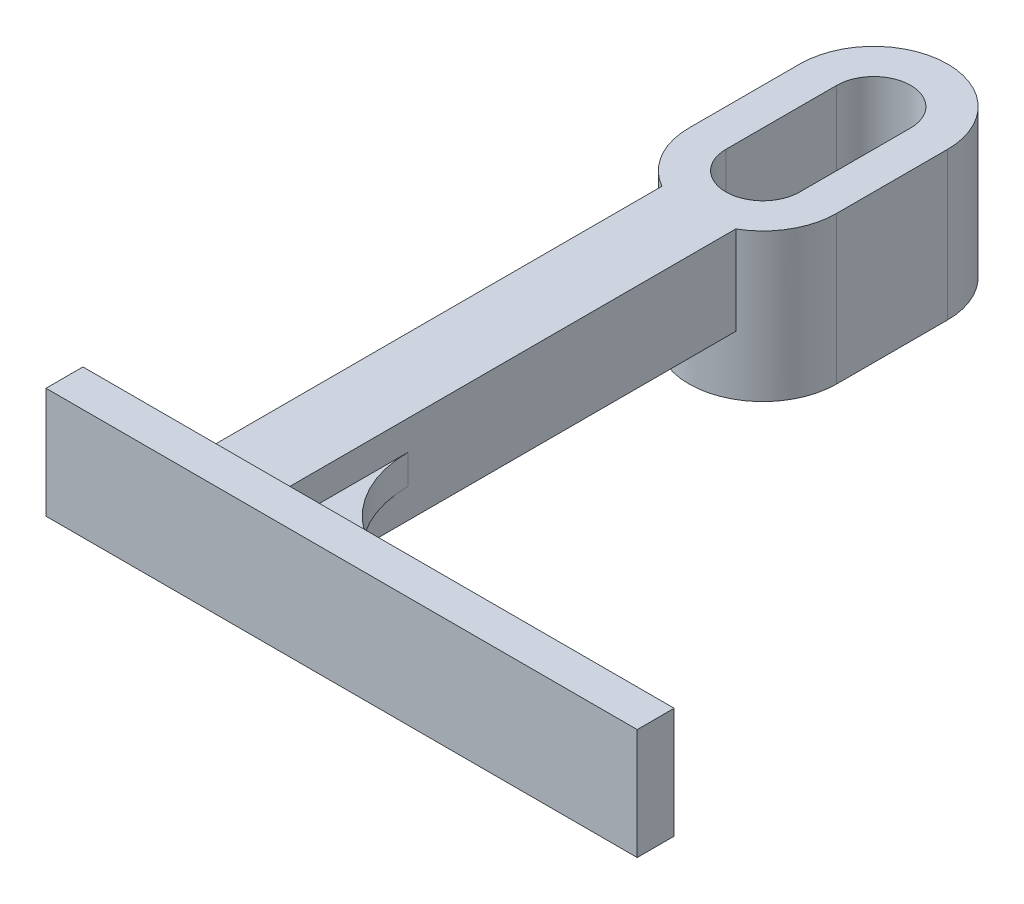
from build123d import *

# Parameters (mm, degrees)
BOSS_EXTRUDE1_DEPTH = 12
BOSS_EXTRUDE2_DEPTH = 8
SKETCH3_W           = 80
SKETCH3_H           = 5
BOSS_EXTRUDE3_DEPTH = 3
BOSS_EXTRUDE4_DEPTH = 2


with BuildPart() as part:
    # Sketch1 → Boss-Extrude1 (new body)
    with BuildSketch(Plane(origin=(0, 0, 0), x_dir=(1, 0, 0), z_dir=(0, 1, 0))):
        with BuildLine():
            Line((10, -15), (10, 0))
            ThreePointArc((10, 0), (0, 10), (-10, 0))
            Line((-10, 0), (-10, -15))
            ThreePointArc((-10, -15), (-8.660254038, -20), (-5, -23.660254038))
            Line((-5, -23.660254038), (-5, -87))
            Line((-5, -87), (-20, -87))
            Line((-20, -87), (-20, -92))
            Line((-20, -92), (60, -92))
            Line((60, -92), (60, -87))
            Line((60, -87), (5, -87))
            Line((5, -87), (5, -23.660254038))
            ThreePointArc((5, -23.660254038), (8.660254038, -20), (10, -15))
        make_face()
        with BuildLine():
            ThreePointArc((-5, 0), (0, 5), (5, 0))
            Line((5, 0), (5, -15))
            ThreePointArc((5, -15), (0, -20), (-5, -15))
            Line((-5, -15), (-5, 0))
        make_face(mode=Mode.SUBTRACT)
    extrude(amount=BOSS_EXTRUDE1_DEPTH)

    # Sketch2 → Boss-Extrude2 (add)
    with BuildSketch(Plane.XZ):
        with BuildLine():
            Line((10, 15), (10, 0))
            ThreePointArc((10, 0), (0, -10), (-10, 0))
            Line((-10, 0), (-10, 15))
            ThreePointArc((-10, 15), (0, 25), (10, 15))
        make_face()
        with BuildLine():
            Line((-5, 0), (-5, 15))
            ThreePointArc((-5, 15), (0, 20), (5, 15))
            Line((5, 15), (5, 0))
            ThreePointArc((5, 0), (0, -5), (-5, 0))
        make_face(mode=Mode.SUBTRACT)
    extrude(amount=BOSS_EXTRUDE2_DEPTH)

    # Sketch3 → Boss-Extrude3 (add)
    with BuildSketch(Plane(origin=(0, 12, 0), x_dir=(1, 0, 0), z_dir=(0, 1, 0))):
        with Locations((20, -89.5)):
            Rectangle(SKETCH3_W, SKETCH3_H)
    extrude(amount=BOSS_EXTRUDE3_DEPTH)

    # Sketch4 → Boss-Extrude4 (add, symmetric)
    with BuildSketch(Plane(origin=(0, 6, 0), x_dir=(1, 0, 0), z_dir=(0, 1, 0))):
        with BuildLine():
            Line((16.018044496, -82.461812831), (32.5, -87))
            Line((32.5, -87), (5, -87))
            Line((5, -87), (5, -68))
            ThreePointArc((5, -68), (8.068333466, -77.090397886), (16.018044496, -82.461812831))
        make_face()
        with BuildLine():
            Line((-5, -72), (-5, -87))
            Line((-5, -87), (-20, -87))
            ThreePointArc((-20, -87), (-9.393398282, -82.606601718), (-5, -72))
        make_face()
    extrude(amount=BOSS_EXTRUDE4_DEPTH, both=True)


solid = part.part
